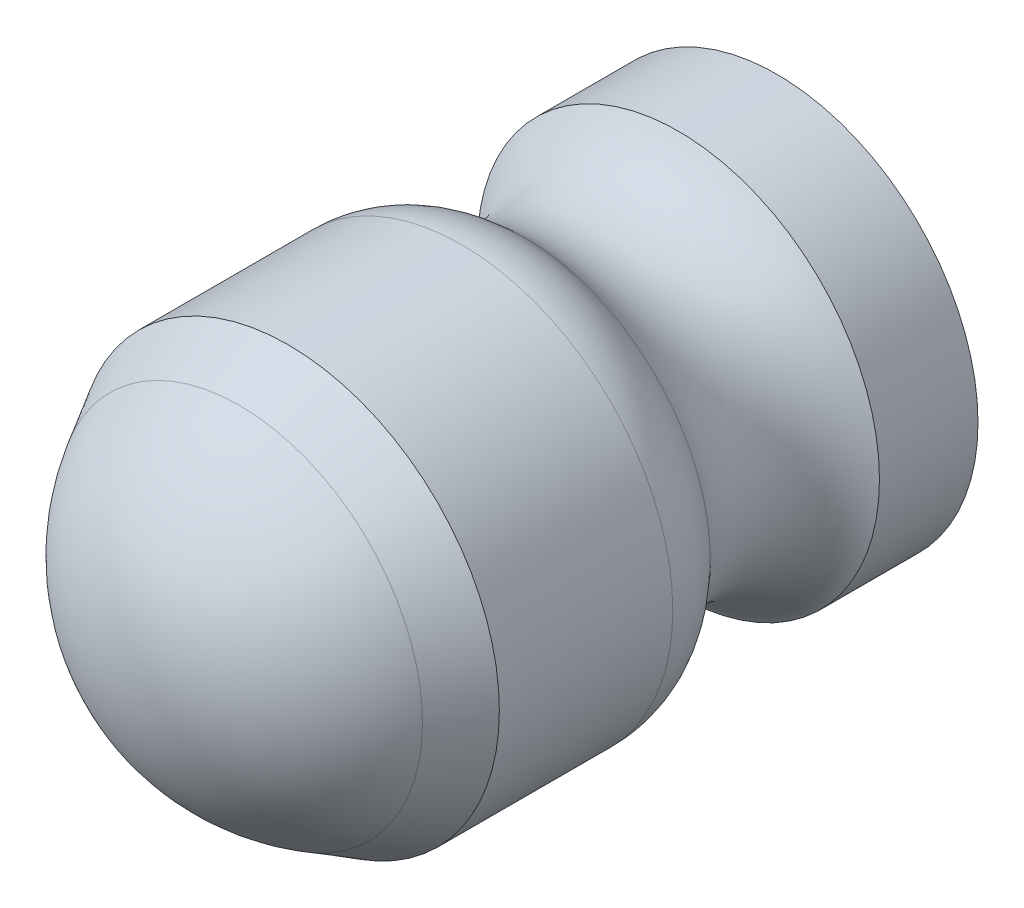
from build123d import *

# Parameters (mm, degrees)
CROQUIS1_R              = 10.5
SALIENTE_EXTRUIR1_DEPTH = 8
CROQUIS5_R              = 3
CORTAR_EXTRUIR1_DEPTH   = 15


with BuildPart() as part:
    # Croquis1 → Saliente-Extruir1 (new body)
    with BuildSketch(Plane.XY):
        Circle(CROQUIS1_R)
    extrude(amount=SALIENTE_EXTRUIR1_DEPTH)

    # Croquis3 → Revolución1 (revolve)
    with BuildSketch(Plane(origin=(0, 0, 0), x_dir=(0, 0, -1), z_dir=(1, 0, 0))):
        with BuildLine():
            Line((-8, 10.5), (-10.428215768, 9.105809129))
            ThreePointArc((-10.428215768, 9.105809129), (-14.286975998, 5.260880841), (-15.7, 0))
            Line((-15.7, 0), (-8, 0))
            Line((-8, 0), (-8, 10.5))
        make_face()
    revolve(axis=Axis((0, 0, 8), (0, 0, 1)))

    # Croquis4 → Revolución2 (revolve)
    with BuildSketch(Plane(origin=(0, 0, 0), x_dir=(0, 0, -1), z_dir=(1, 0, 0))):
        with BuildLine():
            Line((0, 0), (0, 10.5))
            Line((0, 10.5), (0.623533648, 10.5))
            ThreePointArc((0.623533648, 10.5), (2.319891977, 10.168017325), (3.765956272, 9.221052632))
            ThreePointArc((3.765956272, 9.221052632), (7.765081748, 7.825826873), (11.4, 10))
            Line((11.4, 10), (16.3, 10))
            Line((16.3, 10), (16.3, 0))
            Line((16.3, 0), (0, 0))
        make_face()
    revolve(axis=Axis((0, 0, 0), (0, 0, -1)))

    # Croquis5 → Cortar-Extruir1 (cut)
    with BuildSketch(Plane(origin=(0, 0, -16.3), x_dir=(-1, 0, 0), z_dir=(0, 0, -1))):
        Circle(CROQUIS5_R)
    extrude(amount=-CORTAR_EXTRUIR1_DEPTH, mode=Mode.SUBTRACT)


solid = part.part
